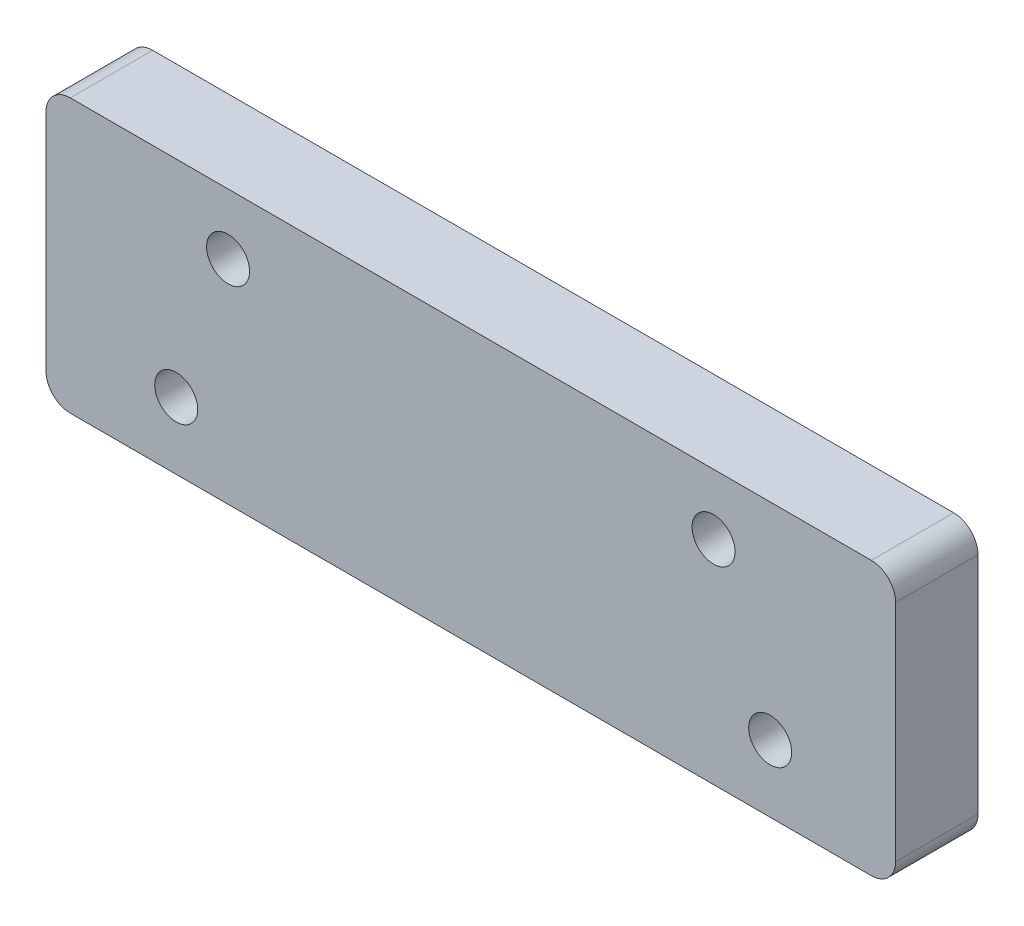
from build123d import *

# Parameters (mm, degrees)
SKETCH1_W                      = 88.9
SKETCH1_H                      = 15.875
BOSS_EXTRUDE1_DEPTH            = 7.62
CBORE_FOR_M4_SHCS1_D           = 4.5
CBORE_FOR_M4_SHCS1_CBORE_D     = 8
CBORE_FOR_M4_SHCS1_CBORE_DEPTH = 4
SKETCH4_W                      = 88.9
SKETCH4_H                      = 15.875
SKETCH4_R                      = 4
BOSS_EXTRUDE2_DEPTH            = 1
SKETCH5_W                      = 88.9
SKETCH5_H                      = 12.7
SKETCH5_R                      = 2
BOSS_EXTRUDE3_DEPTH            = 8.62
M4_CLEARANCE_HOLE1_D           = 4.5
FILLET1_R                      = 2.54


with BuildPart() as part:
    # Sketch1 → Boss-Extrude1 (new body)
    with BuildSketch(Plane.XY):
        with Locations((61.9, 7.9375)):
            Rectangle(SKETCH1_W, SKETCH1_H)
    extrude(amount=-BOSS_EXTRUDE1_DEPTH)

    # CBORE for M4 SHCS1 (through all)
    with Locations(Plane(origin=(0, 0, -7.62), x_dir=(-1, 0, 0), z_dir=(0, 0, -1))):
        with Locations((-93.225, 7), (-31.075, 7)):
            CounterBoreHole(CBORE_FOR_M4_SHCS1_D / 2, CBORE_FOR_M4_SHCS1_CBORE_D / 2, CBORE_FOR_M4_SHCS1_CBORE_DEPTH)

    # Sketch4 → Boss-Extrude2 (add)
    with BuildSketch(Plane(origin=(0, 0, -7.62), x_dir=(-1, 0, 0), z_dir=(0, 0, -1))):
        with Locations((-61.9, 7.9375)):
            Rectangle(SKETCH4_W, SKETCH4_H)
        with Locations((-93.225, 7)):
            Circle(SKETCH4_R, mode=Mode.SUBTRACT)
        with Locations((-31.075, 7)):
            Circle(SKETCH4_R, mode=Mode.SUBTRACT)
    extrude(amount=BOSS_EXTRUDE2_DEPTH)

    # Sketch5 → Boss-Extrude3 (add)
    with BuildSketch(Plane.XY):
        with Locations((61.9, 22.225)):
            Rectangle(SKETCH5_W, SKETCH5_H)
        with Locations((36.5, 22.225)):
            Circle(SKETCH5_R, mode=Mode.SUBTRACT)
        with Locations((87.3, 22.225)):
            Circle(SKETCH5_R, mode=Mode.SUBTRACT)
        with Locations((36.5, 22.225)):
            Circle(SKETCH5_R)
        with Locations((87.3, 22.225)):
            Circle(SKETCH5_R)
    extrude(amount=-BOSS_EXTRUDE3_DEPTH)

    # M4 Clearance Hole1 (through all)
    with Locations(Plane.XY):
        with Locations((36.5, 22.225), (87.3, 22.225)):
            Hole(M4_CLEARANCE_HOLE1_D / 2)

    # Fillet1
    fillet1_edges = [part.edges().sort_by_distance(p)[0] for p in [
        (17.45, 28.575, -4.31),
        (106.35, 28.575, -4.31),
        (106.35, 0, -4.31),
        (17.45, 0, -4.31),
    ]]
    fillet(fillet1_edges, radius=FILLET1_R)


solid = part.part
